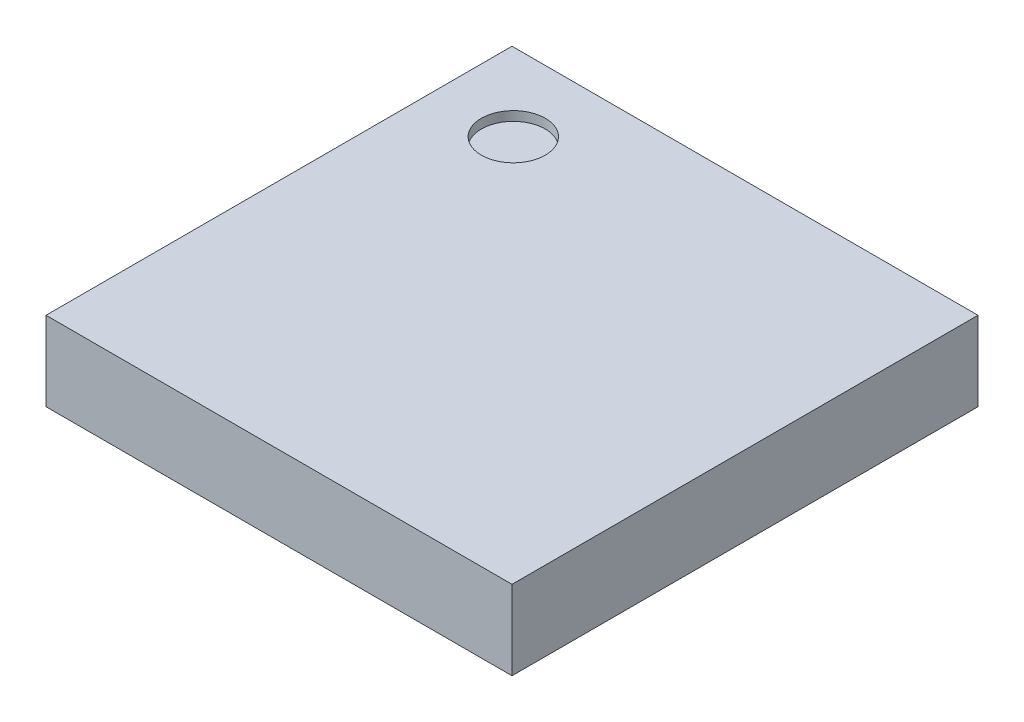
from build123d import *

# Parameters (mm, degrees)
SKETCH1_W           = 5
SKETCH1_H           = 5
BOSS_EXTRUDE1_DEPTH = 0.85
SKETCH2_R           = 0.343107099
CUT_EXTRUDE1_DEPTH  = 0.1


with BuildPart() as part:
    # Sketch1 → Boss-Extrude1 (new body)
    with BuildSketch(Plane(origin=(0, 0, 0), x_dir=(1, 0, 0), z_dir=(0, 1, 0))):
        Rectangle(SKETCH1_W, SKETCH1_H)
    extrude(amount=BOSS_EXTRUDE1_DEPTH)

    # Sketch2 → Cut-Extrude1 (cut)
    with BuildSketch(Plane(origin=(0, 0.85, 0), x_dir=(1, 0, 0), z_dir=(0, 1, 0))):
        with Locations((-1.652078086, 1.666152715)):
            Circle(SKETCH2_R)
    extrude(amount=-CUT_EXTRUDE1_DEPTH, mode=Mode.SUBTRACT)


solid = part.part
